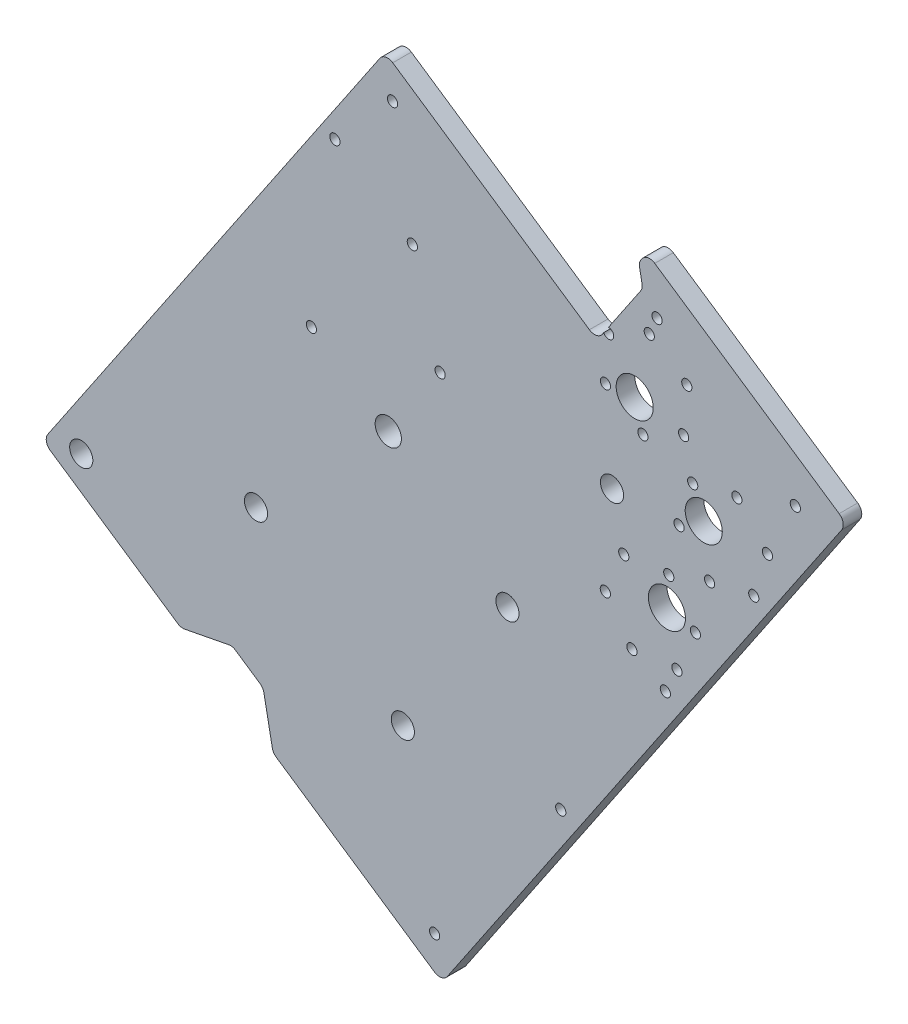
from build123d import *

# Parameters (mm, degrees)
BOSS_EXTRUDE2_DEPTH = 6.35
CUT_EXTRUDE1_DEPTH  = 7.3500001
BOSS_EXTRUDE3_DEPTH = 6.35
SKETCH10_R          = 3.96875
CUT_EXTRUDE2_DEPTH  = 7.35
SKETCH11_R          = 4.5
CUT_EXTRUDE4_DEPTH  = 7.35
BOSS_EXTRUDE4_DEPTH = 6.35
SKETCH13_R          = 1.75
CUT_EXTRUDE5_DEPTH  = 7.35
LPATTERN1_COUNT     = 2
LPATTERN1_PITCH     = 64
SKETCH15_R          = 1.75
CUT_EXTRUDE7_DEPTH  = 7.35
SKETCH16_R          = 1.75
CUT_EXTRUDE8_DEPTH  = 7.35
SKETCH17_R          = 1.75
CUT_EXTRUDE9_DEPTH  = 7.35
SKETCH18_R          = 1.75
SKETCH18_R_2        = 6.35
CUT_EXTRUDE10_DEPTH = 7.35
SKETCH19_R          = 3.96875
CUT_EXTRUDE11_DEPTH = 7.35
SKETCH20_R          = 3.96875
CUT_EXTRUDE12_DEPTH = 7.35
SKETCH21_R          = 5.677654576
BOSS_EXTRUDE5_DEPTH = 6.35
CUT_EXTRUDE13_DEPTH = 7.35
SKETCH23_R          = 1.75
CUT_EXTRUDE14_DEPTH = 7.35
FILLET1_R           = 3.175


with BuildPart() as part:
    # Sketch6 → Boss-Extrude2 (new body)
    with BuildSketch(Plane.XY):
        with BuildLine():
            Line((-68.006850091, -76.67090114), (-109.486767671, -48.656527855))
            Line((-109.486767671, -48.656527855), (-118.371760678, -61.812230963))
            Line((-118.371760678, -61.812230963), (18.447551645, -154.216158235))
            Line((18.447551645, -154.216158235), (135.729459338, 19.43912279))
            Line((135.729459338, 19.43912279), (-1.089852986, 111.843050063))
            Line((-1.089852986, 111.843050063), (-73.946795643, 3.966284577))
            Line((-73.946795643, 3.966284577), (-56.624438948, -7.732749433))
            ThreePointArc((-56.624438948, -7.732749433), (-43.058385537, 37.577891571), (0, 57.15))
            ThreePointArc((0, 57.15), (56.404848571, 31.095576642), (70.829334649, -29.338471048))
            add(Edge.make_bspline(
                [(70.829334649, -29.338471048), (70.811686062, -29.418295928), (70.776015112, -29.578104383), (70.713320217, -29.85478305), (70.619021771, -30.262929245), (70.501052001, -30.762086912), (70.364034474, -31.322191481), (70.199318515, -31.970958926), (70.000453855, -32.723919765), (69.795103485, -33.469783355), (69.582015398, -34.214296028), (69.361377803, -34.956693289), (69.133257682, -35.696762218), (68.838782679, -36.61892651), (68.470566207, -37.720710028), (68.019498024, -38.998776477), (67.474836154, -40.448808619), (66.901337925, -41.887676852), (66.299328392, -43.31485223), (65.669141732, -44.729810424), (65.011119088, -46.132040323), (64.325609411, -47.52103904), (63.612968547, -48.896314904), (62.87355937, -50.257385735), (62.107751613, -51.603779381), (61.315921169, -52.935034173), (60.49845004, -54.250698756), (59.655726138, -55.550331897), (58.571247582, -57.154294757), (57.220953058, -59.045283389), (55.576035723, -61.200397094), (53.604026134, -63.590264702), (51.54329346, -65.904053004), (49.39728314, -68.138962994), (47.169496434, -70.29235602), (44.863486103, -72.361752995), (42.482847363, -74.344831806), (40.031215607, -76.239428526), (36.882516177, -78.494556171), (32.976808929, -81.016011003), (28.250788286, -83.68089187), (21.41551215, -86.919136497), (14.30829026, -89.526654921), (6.996956895, -91.488176442), (-0.451922312, -92.797413176), (-6.61686174, -93.456358442), (-12.81195397, -93.702029749), (-19.009644204, -93.537285056), (-25.183124422, -92.966685286), (-31.306438312, -91.996382122), (-36.598524037, -90.804323442), (-41.072542301, -89.543185606), (-44.752319298, -88.33589156), (-47.664184976, -87.27761875), (-50.541347258, -86.128353728), (-53.381128552, -84.889612663), (-56.180924218, -83.562977818), (-58.593536599, -82.326710176), (-60.633378351, -81.214215821), (-62.313751085, -80.252471782), (-63.646071553, -79.462491566), (-64.966093336, -78.652178853), (-66.222359154, -77.854259082), (-67.143044791, -77.250601571), (-67.736251212, -76.85365602), (-68.006850091, -76.67090114)],
                knots=[0.071020771, 0.071020771, 0.071020771, 0.071020771, 0.071020771, 0.072848477, 0.074676184, 0.07650389, 0.078331597, 0.08198701, 0.085642423, 0.089297836, 0.092953249, 0.096608662, 0.100264075, 0.103919488, 0.107574901, 0.114885727, 0.122196554, 0.12950738, 0.136818214, 0.144129048, 0.151439882, 0.158750716, 0.166061558, 0.173372401, 0.180683243, 0.187994085, 0.195304924, 0.202615763, 0.209926602, 0.217237441, 0.231859103, 0.246480766, 0.261102426, 0.275724085, 0.290345754, 0.304967424, 0.319589099, 0.334210774, 0.348832457, 0.36345414, 0.392697464, 0.421940789, 0.451184112, 0.506140643, 0.535383973, 0.564627303, 0.593870641, 0.623113979, 0.652357319, 0.68160066, 0.710843985, 0.740087309, 0.754708984, 0.769330659, 0.783952333, 0.798574008, 0.813195669, 0.82781733, 0.842438991, 0.849749821, 0.857060652, 0.86437149, 0.871682327, 0.878993165, 0.885158103, 0.885158103, 0.885158103, 0.885158103, 0.885158103], degree=4))
        make_face()
    extrude(amount=BOSS_EXTRUDE2_DEPTH)

    # Sketch8 → Cut-Extrude1 (cut, through all)
    with BuildSketch(Plane.XY.offset(6.35)):
        Polygon((-71.011229489, -93.798205788), (-53.378672597, -90.381637707), (-42.854110111, -97.489632113), (-39.43754203, -115.122189004), align=None)
    extrude(amount=-CUT_EXTRUDE1_DEPTH, mode=Mode.SUBTRACT)

    # Sketch9 → Boss-Extrude3 (add, through all)
    with BuildSketch(Plane.XY.offset(6.35)):
        Polygon((-1.089852986, 111.843050063), (-109.486767671, -48.656527855), (27.332544652, -141.060455127), (135.729459338, 19.43912279), align=None)
    extrude(amount=-BOSS_EXTRUDE3_DEPTH)

    # Sketch10 → Cut-Extrude2 (cut, through all)
    with BuildSketch(Plane.XY.offset(6.35)):
        with Locations((4.996496209, -84.796642912)):
            Circle(SKETCH10_R)
        with Locations((40.816310536, -31.759477627)):
            Circle(SKETCH10_R)
        with Locations((76.636124864, 21.277687659)):
            Circle(SKETCH10_R)
        with Locations((-45.295165913, -45.214466102)):
            Circle(SKETCH10_R)
    extrude(amount=-CUT_EXTRUDE2_DEPTH, mode=Mode.SUBTRACT)

    # Sketch11 → Cut-Extrude4 (cut, through all)
    with BuildSketch(Plane.XY.offset(6.35)):
        Circle(SKETCH11_R)
    extrude(amount=-CUT_EXTRUDE4_DEPTH, mode=Mode.SUBTRACT)

    # Sketch12 → Boss-Extrude4 (add, through all)
    with BuildSketch(Plane.XY.offset(6.35)):
        Polygon((135.729459338, 19.43912279), (67.319803176, 65.641086427), (88.643786393, 97.214773886), (157.053442554, 51.01281025), align=None)
    extrude(amount=-BOSS_EXTRUDE4_DEPTH)

    # Sketch13 → Cut-Extrude5 (cut, through all)
    with BuildSketch(Plane.XY.offset(6.35)):
        with Locations((94.899221836, -29.671127724)):
            Circle(SKETCH13_R)
    cut_extrude5 = extrude(amount=-CUT_EXTRUDE5_DEPTH, mode=Mode.SUBTRACT)

    # LPattern1: Cut-Extrude5 ×2
    with Locations(*[Vector(-0.559684599, -0.828705708, 0) * (i * LPATTERN1_PITCH) for i in range(1, LPATTERN1_COUNT)]):
        add(cut_extrude5, mode=Mode.SUBTRACT)

    # Sketch15 → Cut-Extrude7 (cut, through all)
    with BuildSketch(Plane.XY.offset(6.35)):
        with Locations((-105.147343009, -59.249804902)):
            Circle(SKETCH15_R)
        with Locations((15.885125585, -140.991740566)):
            Circle(SKETCH15_R)
        with Locations((1.472573075, 98.618632394)):
            Circle(SKETCH15_R)
    extrude(amount=-CUT_EXTRUDE7_DEPTH, mode=Mode.SUBTRACT)

    # Sketch16 → Cut-Extrude8 (cut, through all)
    with BuildSketch(Plane.XY.offset(6.35)):
        with Locations((92.060354474, 79.582216994)):
            Circle(SKETCH16_R)
        with Locations((139.420885662, 47.596242169)):
            Circle(SKETCH16_R)
    extrude(amount=-CUT_EXTRUDE8_DEPTH, mode=Mode.SUBTRACT)

    # Sketch17 → Cut-Extrude9 (cut, through all)
    with BuildSketch(Plane.XY.offset(6.35)):
        with Locations((-26.311406216, 17.769986014)):
            Circle(SKETCH17_R)
        with Locations((17.769986014, 26.311406216)):
            Circle(SKETCH17_R)
    extrude(amount=-CUT_EXTRUDE9_DEPTH, mode=Mode.SUBTRACT)

    # Sketch18 → Cut-Extrude10 (cut, through all)
    with BuildSketch(Plane.XY.offset(6.35)):
        with Locations((75.468896753, 66.798604333)):
            Circle(SKETCH18_R)
        with Locations((74.378499235, 51.337005669)):
            Circle(SKETCH18_R)
        with Locations((87.223437703, 42.661894386)):
            Circle(SKETCH18_R)
        with Locations((101.158773688, 49.448381768)):
            Circle(SKETCH18_R)
        with Locations((102.249171205, 64.909980432)):
            Circle(SKETCH18_R)
        with Locations((89.404232738, 73.585091715)):
            Circle(SKETCH18_R)
        with Locations((99.589076537, 21.914747078)):
            Circle(SKETCH18_R)
        with Locations((104.266720973, 36.692082512)):
            Circle(SKETCH18_R)
        with Locations((119.403091077, 40.029791318)):
            Circle(SKETCH18_R)
        with Locations((129.861816745, 28.59016469)):
            Circle(SKETCH18_R)
        with Locations((125.18417231, 13.812829255)):
            Circle(SKETCH18_R)
        with Locations((110.047802206, 10.47512045)):
            Circle(SKETCH18_R)
        with Locations((105.180381325, -7.122099496)):
            Circle(SKETCH18_R)
        with Locations((96.077150237, 5.423066257)):
            Circle(SKETCH18_R)
        with Locations((80.661102457, 3.812019754)):
            Circle(SKETCH18_R)
        with Locations((74.348285765, -10.344192501)):
            Circle(SKETCH18_R)
        with Locations((83.451516853, -22.889358254)):
            Circle(SKETCH18_R)
        with Locations((98.867564633, -21.278311751)):
            Circle(SKETCH18_R)
        with Locations((84.396043028, 52.322553097)):
            Circle(SKETCH18_R_2)
        with Locations((108.051811284, 27.364940468)):
            Circle(SKETCH18_R_2)
        with Locations((95.429892272, -4.622009378)):
            Circle(SKETCH18_R_2)
    extrude(amount=-CUT_EXTRUDE10_DEPTH, mode=Mode.SUBTRACT)

    # Sketch19 → Cut-Extrude11 (cut, through all)
    with BuildSketch(Plane.XY.offset(6.35)):
        with Locations((-65.680233685, -85.904783923)):
            Circle(SKETCH19_R)
    extrude(amount=-CUT_EXTRUDE11_DEPTH, mode=Mode.SUBTRACT)

    # Sketch20 → Cut-Extrude12 (cut, through all)
    with BuildSketch(Plane.XY.offset(6.35)):
        with Locations((-105.147343009, -59.249804902)):
            Circle(SKETCH20_R)
    extrude(amount=-CUT_EXTRUDE12_DEPTH, mode=Mode.SUBTRACT)

    # Sketch21 → Boss-Extrude5 (add, through all)
    with BuildSketch(Plane.XY.offset(6.35)):
        with Locations((-65.680233685, -85.904783923)):
            Circle(SKETCH21_R)
    extrude(amount=-BOSS_EXTRUDE5_DEPTH)

    # Sketch22 → Cut-Extrude13 (cut, through all)
    with BuildSketch(Plane.XY.offset(6.35)):
        Polygon((85.800588631, 93.004948891), (87.167215863, 85.951926135), (71.529628171, 62.797888664), (67.319803176, 65.641086427), align=None)
    extrude(amount=-CUT_EXTRUDE13_DEPTH, mode=Mode.SUBTRACT)

    # Sketch23 → Cut-Extrude14 (cut, through all)
    with BuildSketch(Plane(origin=(0, 0, 0), x_dir=(-1, 0, 0), z_dir=(0, 0, -1))):
        with Locations((-8.248274978, 59.561032446)):
            Circle(SKETCH23_R)
        with Locations((18.270307664, 77.470939609)):
            Circle(SKETCH23_R)
    extrude(amount=-CUT_EXTRUDE14_DEPTH, mode=Mode.SUBTRACT)

    # Fillet1
    fillet1_edges = [part.edges().sort_by_distance(p)[0] for p in [
        (-1.089852986, 111.843050063, 3.175),
        (18.447551645, -154.216158235, 3.175),
        (-118.371760678, -61.812230963, 3.175),
        (87.167215863, 85.951926135, 3.175),
        (85.800588631, 93.004948891, 3.175),
        (71.529628171, 62.797888664, 3.175),
        (-39.43754203, -115.122189004, 3.175),
        (-71.011229489, -93.798205788, 3.175),
        (-53.378672597, -90.381637707, 3.175),
        (-42.854110111, -97.489632113, 3.175),
        (157.053442554, 51.01281025, 3.175),
        (88.643786393, 97.214773886, 3.175),
    ]]
    fillet(fillet1_edges, radius=FILLET1_R)


solid = part.part
